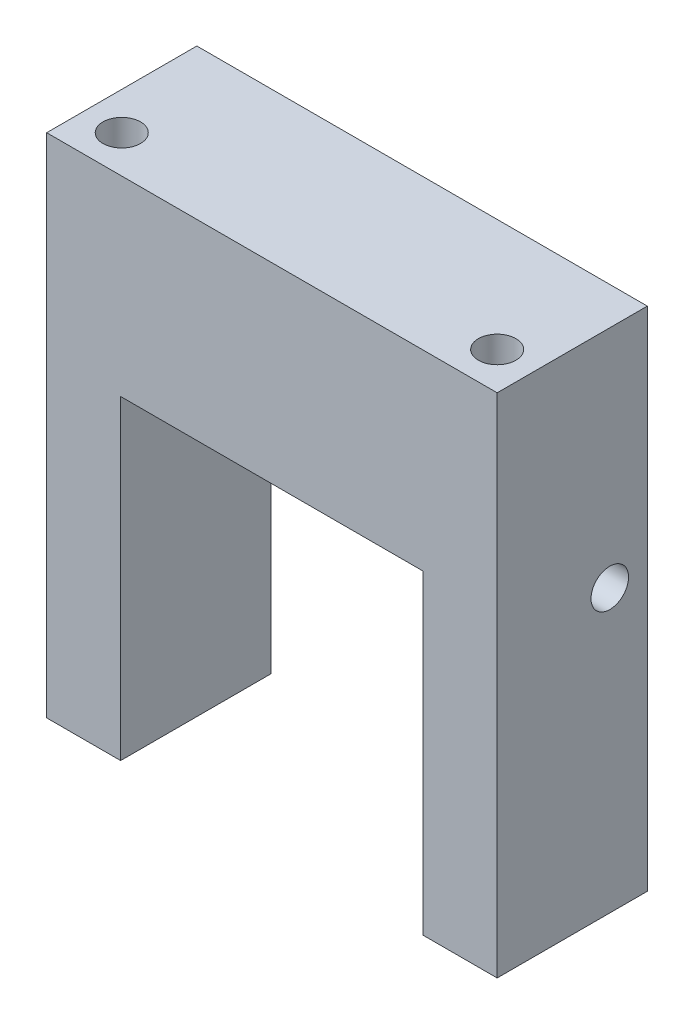
from build123d import *

# Parameters (mm, degrees)
BOSS_EXTRUDE1_DEPTH = 20
SKETCH3_R           = 2.5
CUT_EXTRUDE1_DEPTH  = 68.5
SKETCH4_R           = 2.5
CUT_EXTRUDE2_DEPTH  = 61


with BuildPart() as part:
    # Sketch1 → Boss-Extrude1 (new body)
    with BuildSketch(Plane.XY):
        Polygon((50.15, 0), (60, 0), (60, 67.5), (0, 67.5), (0, 0), (9.85, 0), (9.85, 42), (50.15, 42), align=None)
    extrude(amount=BOSS_EXTRUDE1_DEPTH)

    # Sketch3 → Cut-Extrude1 (cut, through all)
    with BuildSketch(Plane.XZ):
        with Locations((5, 15)):
            Circle(SKETCH3_R)
        with Locations((55, 15)):
            Circle(SKETCH3_R)
    extrude(amount=-CUT_EXTRUDE1_DEPTH, mode=Mode.SUBTRACT)

    # Sketch4 → Cut-Extrude2 (cut, through all)
    with BuildSketch(Plane.ZY):
        with Locations((5, 37.5)):
            Circle(SKETCH4_R)
    extrude(amount=-CUT_EXTRUDE2_DEPTH, mode=Mode.SUBTRACT)


solid = part.part
